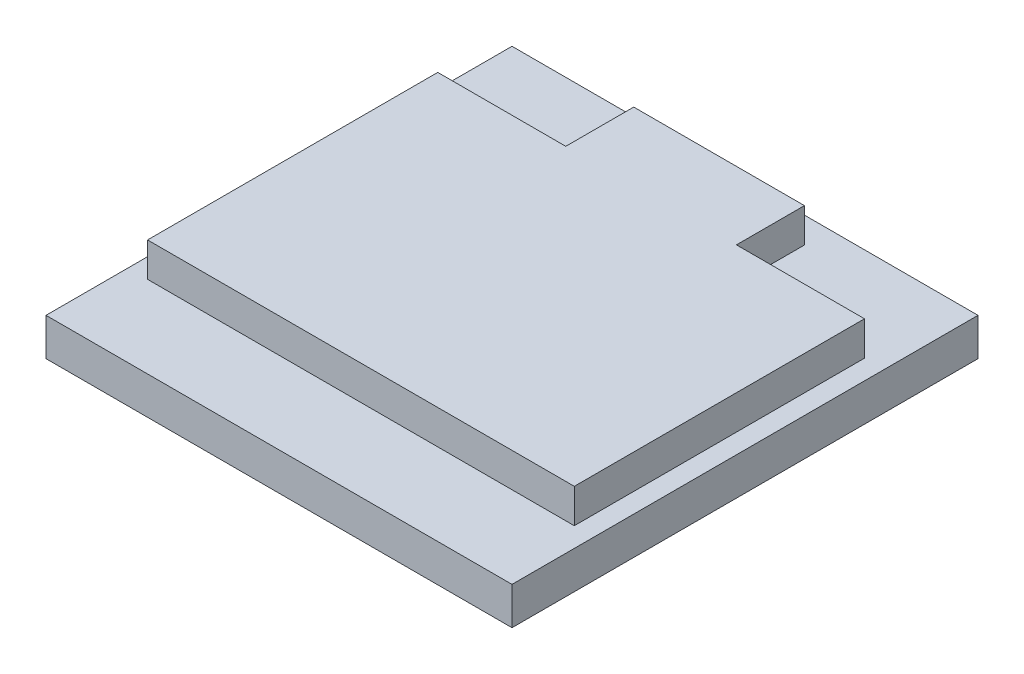
from build123d import *

# Parameters (mm, degrees)
SKETCH1_W           = 27.3
SKETCH1_H           = 27.3
BOSS_EXTRUDE1_DEPTH = 2.2
SKETCH2_W           = 10
SKETCH2_H           = 3.982118458
BOSS_EXTRUDE3_DEPTH = 2


with BuildPart() as part:
    # Sketch1 → Boss-Extrude1 (new body)
    with BuildSketch(Plane(origin=(0, 0, 0), x_dir=(1, 0, 0), z_dir=(0, 1, 0))):
        Rectangle(SKETCH1_W, SKETCH1_H)
    extrude(amount=BOSS_EXTRUDE1_DEPTH)

    # Sketch2 → Boss-Extrude3 (add)
    with BuildSketch(Plane(origin=(0, 2.2, 0), x_dir=(1, 0, 0), z_dir=(0, 1, 0))):
        with Locations((0, 10.141059229)):
            Rectangle(SKETCH2_W, SKETCH2_H)
        Polygon((-12.5, 8.15), (-12.5, -8.85), (12.5, -8.85), (12.5, 8.15), (5, 8.15), (5, 4.167881542), (-5, 4.167881542), (-5, 8.15), align=None)
        with Locations((0, 6.158940771)):
            Rectangle(SKETCH2_W, SKETCH2_H)
    extrude(amount=BOSS_EXTRUDE3_DEPTH)


solid = part.part
